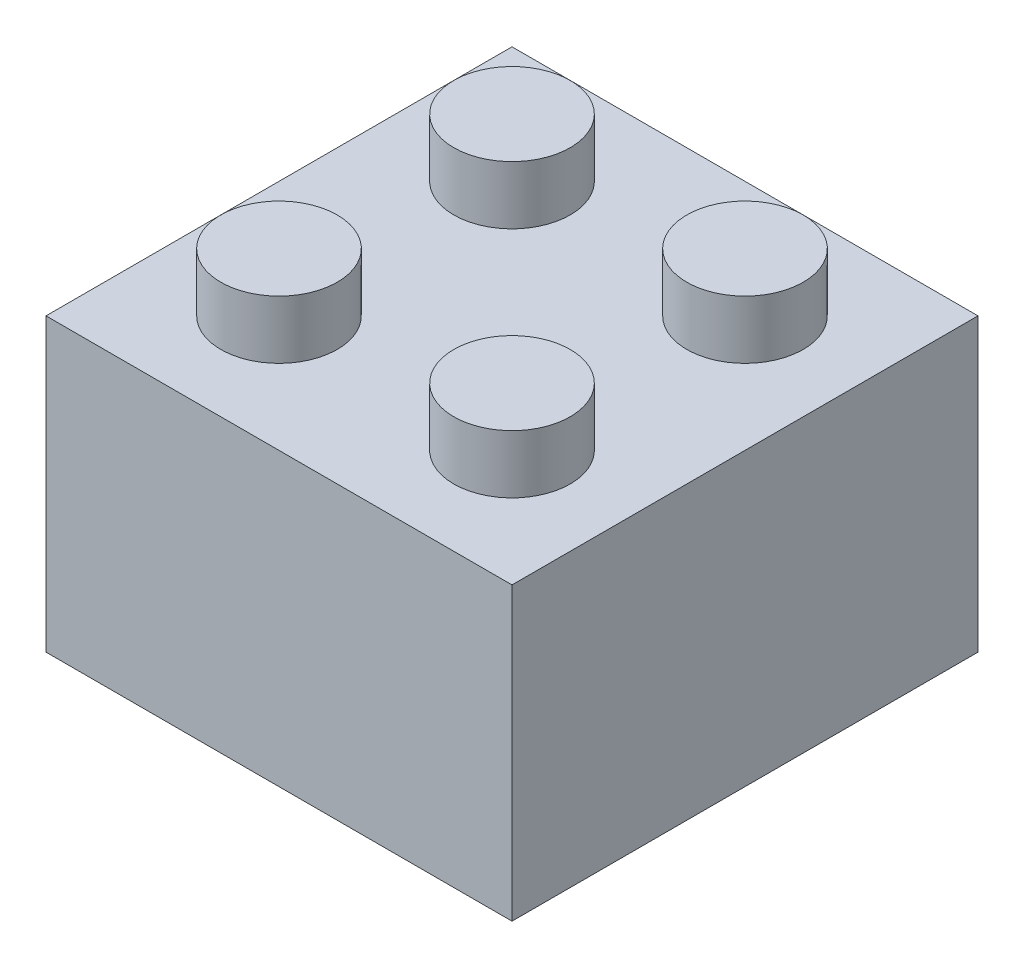
from build123d import *

# Parameters (mm, degrees)
SKETCH1_W           = 16
SKETCH1_H           = 16
BOSS_EXTRUDE1_DEPTH = 10
SKETCH2_R           = 2
BOSS_EXTRUDE2_DEPTH = 2
SHELL1_T            = -1
SKETCH3_R           = 2.7
SKETCH3_R_2         = 1.7
BOSS_EXTRUDE3_DEPTH = 9


with BuildPart() as part:
    # Sketch1 → Boss-Extrude1 (new body)
    with BuildSketch(Plane(origin=(0, 0, 0), x_dir=(1, 0, 0), z_dir=(0, 1, 0))):
        Rectangle(SKETCH1_W, SKETCH1_H)
    extrude(amount=BOSS_EXTRUDE1_DEPTH)

    # Sketch2 → Boss-Extrude2 (add)
    with BuildSketch(Plane(origin=(0, 10, 0), x_dir=(1, 0, 0), z_dir=(0, 1, 0))):
        with Locations((-4, 4)):
            Circle(SKETCH2_R)
        with Locations((4, 4)):
            Circle(SKETCH2_R)
        with Locations((-4, -4)):
            Circle(SKETCH2_R)
        with Locations((4, -4)):
            Circle(SKETCH2_R)
    extrude(amount=BOSS_EXTRUDE2_DEPTH)

    # Shell1
    shell1_openings = [part.faces().sort_by_distance(p)[0] for p in [
        (0, 0, 0),
    ]]
    offset(amount=SHELL1_T, openings=shell1_openings, kind=Kind.INTERSECTION)

    # Sketch3 → Boss-Extrude3 (add)
    with BuildSketch(Plane.XZ.offset(-9)):
        Circle(SKETCH3_R)
        Circle(SKETCH3_R_2, mode=Mode.SUBTRACT)
    extrude(amount=BOSS_EXTRUDE3_DEPTH)


solid = part.part
